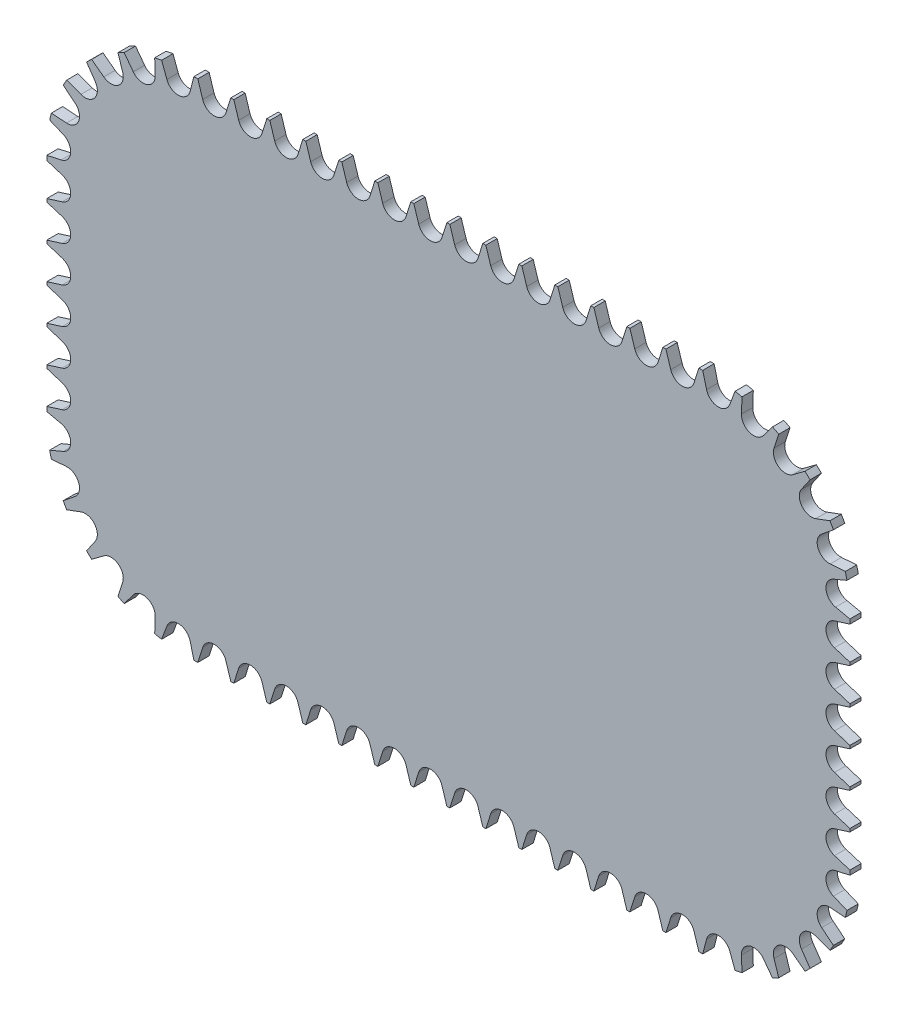
from build123d import *

# Parameters (mm, degrees)
AUFSATZ_LINEAR_AUSTRAGEN1_DEPTH = 4
SCHNITT_LINEAR_AUSTRAGEN1_DEPTH = 5
SPIEGELN2_COPY_1_DEPTH          = 5
SKIZZE4_OUTSIDE_W               = 354.422
SKIZZE4_OUTSIDE_H               = 249.422
SCHNITT_LINEAR_AUSTRAGEN2_DEPTH = 5


with BuildPart() as part:
    # Skizze1 → Aufsatz-Linear austragen1 (new body)
    with BuildSketch(Plane.XY):
        with BuildLine():
            Line((-92.5, -90), (92.5, -90))
            ThreePointArc((92.5, -90), (127.855339059, -75.355339059), (142.5, -40))
            Line((142.5, -40), (142.5, 40))
            ThreePointArc((142.5, 40), (127.855339059, 75.355339059), (92.5, 90))
            Line((92.5, 90), (-92.5, 90))
            ThreePointArc((-92.5, 90), (-127.855339059, 75.355339059), (-142.5, 40))
            Line((-142.5, 40), (-142.5, -40))
            ThreePointArc((-142.5, -40), (-127.855339059, -75.355339059), (-92.5, -90))
        make_face()
    extrude(amount=AUFSATZ_LINEAR_AUSTRAGEN1_DEPTH)

    # Skizze3 → Schnitt-Linear austragen1 (cut, through all)
    with BuildSketch(Plane.XY.offset(4)):
        with BuildLine():
            Line((-12.49822894, 90.2), (-10.450982888, 83.706965062))
            ThreePointArc((-10.450982888, 83.706965062), (-6.35, 80.7), (-2.249017112, 83.706965062))
            Line((-2.249017112, 83.706965062), (-0.20177106, 90.2))
            Line((-0.20177106, 90.2), (-12.49822894, 90.2))
        make_face()
        with BuildLine():
            Line((-115.221743509, 85.348794759), (-111.138194894, 79.901286172))
            ThreePointArc((-111.138194894, 79.901286172), (-106.27239465, 78.423487971), (-103.399819104, 82.619701654))
            Line((-103.399819104, 82.619701654), (-103.620303737, 89.424266712))
            Line((-103.620303737, 89.424266712), (-115.221743509, 85.348794759))
        make_face()
        with BuildLine():
            Line((-101.660918042, 89.872458206), (-99.2780093, 83.494961437))
            ThreePointArc((-99.2780093, 83.494961437), (-95.025864968, 80.705845428), (-91.087193292, 83.922484196))
            Line((-91.087193292, 83.922484196), (-89.381175989, 90.513404015))
            Line((-89.381175989, 90.513404015), (-101.660918042, 89.872458206))
        make_face()
        with BuildLine():
            Line((-126.985611723, 77.237422279), (-121.53161279, 73.162546239))
            ThreePointArc((-121.53161279, 73.162546239), (-116.446555008, 73.11686374), (-114.873880469, 77.95283255))
            Line((-114.873880469, 77.95283255), (-117.004281967, 84.419060861))
            Line((-117.004281967, 84.419060861), (-126.985611723, 77.237422279))
        make_face()
        with BuildLine():
            Line((-135.984667036, 66.137874436), (-129.602914915, 63.766385669))
            ThreePointArc((-129.602914915, 63.766385669), (-124.71135004, 65.156526888), (-124.566229357, 70.239718751))
            Line((-124.566229357, 70.239718751), (-128.433624578, 75.842751262))
            Line((-128.433624578, 75.842751262), (-135.984667036, 66.137874436))
        make_face()
        with BuildLine():
            Line((-141.488462669, 52.95109346), (-134.696959542, 52.475483988))
            ThreePointArc((-134.696959542, 52.475483988), (-130.395932339, 55.188612171), (-131.690144853, 60.106428099))
            Line((-131.690144853, 60.106428099), (-136.980620138, 64.391470732))
            Line((-136.980620138, 64.391470732), (-141.488462669, 52.95109346))
        make_face()
        with BuildLine():
            Line((-143.232042394, 38.794523972), (-136.581155829, 40.249318461))
            ThreePointArc((-136.581155829, 40.249318461), (-133.217437041, 44.063147961), (-135.843261134, 48.418024235))
            Line((-135.843261134, 48.418024235), (-142.125784298, 51.04111817))
            Line((-142.125784298, 51.04111817), (-143.232042394, 38.794523972))
        make_face()
        with BuildLine():
            Line((-142.7, 25.60177106), (-136.206965062, 27.649017112))
            ThreePointArc((-136.206965062, 27.649017112), (-133.2, 31.75), (-136.206965062, 35.850982888))
            Line((-136.206965062, 35.850982888), (-142.7, 37.89822894))
            Line((-142.7, 37.89822894), (-142.7, 25.60177106))
        make_face()
        with BuildLine():
            Line((-142.7, 12.90177106), (-136.206965062, 14.949017112))
            ThreePointArc((-136.206965062, 14.949017112), (-133.2, 19.05), (-136.206965062, 23.150982888))
            Line((-136.206965062, 23.150982888), (-142.7, 25.19822894))
            Line((-142.7, 25.19822894), (-142.7, 12.90177106))
        make_face()
        with BuildLine():
            Line((-142.7, 0.20177106), (-136.206965062, 2.249017112))
            ThreePointArc((-136.206965062, 2.249017112), (-133.2, 6.35), (-136.206965062, 10.450982888))
            Line((-136.206965062, 10.450982888), (-142.7, 12.49822894))
            Line((-142.7, 12.49822894), (-142.7, 0.20177106))
        make_face()
        with BuildLine():
            Line((-25.19822894, 90.2), (-23.150982888, 83.706965062))
            ThreePointArc((-23.150982888, 83.706965062), (-19.05, 80.7), (-14.949017112, 83.706965062))
            Line((-14.949017112, 83.706965062), (-12.90177106, 90.2))
            Line((-12.90177106, 90.2), (-25.19822894, 90.2))
        make_face()
        with BuildLine():
            Line((-37.89822894, 90.2), (-35.850982888, 83.706965062))
            ThreePointArc((-35.850982888, 83.706965062), (-31.75, 80.7), (-27.649017112, 83.706965062))
            Line((-27.649017112, 83.706965062), (-25.60177106, 90.2))
            Line((-25.60177106, 90.2), (-37.89822894, 90.2))
        make_face()
        with BuildLine():
            Line((-50.59822894, 90.2), (-48.550982888, 83.706965062))
            ThreePointArc((-48.550982888, 83.706965062), (-44.45, 80.7), (-40.349017112, 83.706965062))
            Line((-40.349017112, 83.706965062), (-38.30177106, 90.2))
            Line((-38.30177106, 90.2), (-50.59822894, 90.2))
        make_face()
        with BuildLine():
            Line((-63.29822894, 90.2), (-61.250982888, 83.706965062))
            ThreePointArc((-61.250982888, 83.706965062), (-57.15, 80.7), (-53.049017112, 83.706965062))
            Line((-53.049017112, 83.706965062), (-51.00177106, 90.2))
            Line((-51.00177106, 90.2), (-63.29822894, 90.2))
        make_face()
        with BuildLine():
            Line((-75.99822894, 90.2), (-73.950982888, 83.706965062))
            ThreePointArc((-73.950982888, 83.706965062), (-69.85, 80.7), (-65.749017112, 83.706965062))
            Line((-65.749017112, 83.706965062), (-63.70177106, 90.2))
            Line((-63.70177106, 90.2), (-75.99822894, 90.2))
        make_face()
        with BuildLine():
            Line((-88.69822894, 90.2), (-86.650982888, 83.706965062))
            ThreePointArc((-86.650982888, 83.706965062), (-82.55, 80.7), (-78.449017112, 83.706965062))
            Line((-78.449017112, 83.706965062), (-76.40177106, 90.2))
            Line((-76.40177106, 90.2), (-88.69822894, 90.2))
        make_face()
    schnitt_linear_austragen1 = extrude(amount=-SCHNITT_LINEAR_AUSTRAGEN1_DEPTH, mode=Mode.SUBTRACT)

    # Spiegeln1: Schnitt-Linear austragen1 across plane
    add(schnitt_linear_austragen1.mirror(Plane.ZX), mode=Mode.SUBTRACT)

    # Spiegeln2: Schnitt-Linear austragen1 across plane
    add(schnitt_linear_austragen1.mirror(Plane(origin=(0, 0, 0), x_dir=(0, 0, 1), z_dir=(1, 0, 0))), mode=Mode.SUBTRACT)

    # Spiegeln2 copy 1 sketch → Spiegeln2 copy 1 (cut, through all)
    with BuildSketch(Plane(origin=(0, 0, 4), x_dir=(-1, 0, 0), z_dir=(0, 0, 1))):
        with BuildLine():
            Line((-12.49822894, 90.2), (-10.450982888, 83.706965062))
            ThreePointArc((-10.450982888, 83.706965062), (-6.35, 80.7), (-2.249017112, 83.706965062))
            Line((-2.249017112, 83.706965062), (-0.20177106, 90.2))
            Line((-0.20177106, 90.2), (-12.49822894, 90.2))
        make_face()
        with BuildLine():
            Line((-115.221743509, 85.348794759), (-111.138194894, 79.901286172))
            ThreePointArc((-111.138194894, 79.901286172), (-106.27239465, 78.423487971), (-103.399819104, 82.619701654))
            Line((-103.399819104, 82.619701654), (-103.620303737, 89.424266712))
            Line((-103.620303737, 89.424266712), (-115.221743509, 85.348794759))
        make_face()
        with BuildLine():
            Line((-101.660918042, 89.872458206), (-99.2780093, 83.494961437))
            ThreePointArc((-99.2780093, 83.494961437), (-95.025864968, 80.705845428), (-91.087193292, 83.922484196))
            Line((-91.087193292, 83.922484196), (-89.381175989, 90.513404015))
            Line((-89.381175989, 90.513404015), (-101.660918042, 89.872458206))
        make_face()
        with BuildLine():
            Line((-126.985611723, 77.237422279), (-121.53161279, 73.162546239))
            ThreePointArc((-121.53161279, 73.162546239), (-116.446555008, 73.11686374), (-114.873880469, 77.95283255))
            Line((-114.873880469, 77.95283255), (-117.004281967, 84.419060861))
            Line((-117.004281967, 84.419060861), (-126.985611723, 77.237422279))
        make_face()
        with BuildLine():
            Line((-135.984667036, 66.137874436), (-129.602914915, 63.766385669))
            ThreePointArc((-129.602914915, 63.766385669), (-124.71135004, 65.156526888), (-124.566229357, 70.239718751))
            Line((-124.566229357, 70.239718751), (-128.433624578, 75.842751262))
            Line((-128.433624578, 75.842751262), (-135.984667036, 66.137874436))
        make_face()
        with BuildLine():
            Line((-141.488462669, 52.95109346), (-134.696959542, 52.475483988))
            ThreePointArc((-134.696959542, 52.475483988), (-130.395932339, 55.188612171), (-131.690144853, 60.106428099))
            Line((-131.690144853, 60.106428099), (-136.980620138, 64.391470732))
            Line((-136.980620138, 64.391470732), (-141.488462669, 52.95109346))
        make_face()
        with BuildLine():
            Line((-143.232042394, 38.794523972), (-136.581155829, 40.249318461))
            ThreePointArc((-136.581155829, 40.249318461), (-133.217437041, 44.063147961), (-135.843261134, 48.418024235))
            Line((-135.843261134, 48.418024235), (-142.125784298, 51.04111817))
            Line((-142.125784298, 51.04111817), (-143.232042394, 38.794523972))
        make_face()
        with BuildLine():
            Line((-142.7, 25.60177106), (-136.206965062, 27.649017112))
            ThreePointArc((-136.206965062, 27.649017112), (-133.2, 31.75), (-136.206965062, 35.850982888))
            Line((-136.206965062, 35.850982888), (-142.7, 37.89822894))
            Line((-142.7, 37.89822894), (-142.7, 25.60177106))
        make_face()
        with BuildLine():
            Line((-142.7, 12.90177106), (-136.206965062, 14.949017112))
            ThreePointArc((-136.206965062, 14.949017112), (-133.2, 19.05), (-136.206965062, 23.150982888))
            Line((-136.206965062, 23.150982888), (-142.7, 25.19822894))
            Line((-142.7, 25.19822894), (-142.7, 12.90177106))
        make_face()
        with BuildLine():
            Line((-142.7, 0.20177106), (-136.206965062, 2.249017112))
            ThreePointArc((-136.206965062, 2.249017112), (-133.2, 6.35), (-136.206965062, 10.450982888))
            Line((-136.206965062, 10.450982888), (-142.7, 12.49822894))
            Line((-142.7, 12.49822894), (-142.7, 0.20177106))
        make_face()
        with BuildLine():
            Line((-25.19822894, 90.2), (-23.150982888, 83.706965062))
            ThreePointArc((-23.150982888, 83.706965062), (-19.05, 80.7), (-14.949017112, 83.706965062))
            Line((-14.949017112, 83.706965062), (-12.90177106, 90.2))
            Line((-12.90177106, 90.2), (-25.19822894, 90.2))
        make_face()
        with BuildLine():
            Line((-37.89822894, 90.2), (-35.850982888, 83.706965062))
            ThreePointArc((-35.850982888, 83.706965062), (-31.75, 80.7), (-27.649017112, 83.706965062))
            Line((-27.649017112, 83.706965062), (-25.60177106, 90.2))
            Line((-25.60177106, 90.2), (-37.89822894, 90.2))
        make_face()
        with BuildLine():
            Line((-50.59822894, 90.2), (-48.550982888, 83.706965062))
            ThreePointArc((-48.550982888, 83.706965062), (-44.45, 80.7), (-40.349017112, 83.706965062))
            Line((-40.349017112, 83.706965062), (-38.30177106, 90.2))
            Line((-38.30177106, 90.2), (-50.59822894, 90.2))
        make_face()
        with BuildLine():
            Line((-63.29822894, 90.2), (-61.250982888, 83.706965062))
            ThreePointArc((-61.250982888, 83.706965062), (-57.15, 80.7), (-53.049017112, 83.706965062))
            Line((-53.049017112, 83.706965062), (-51.00177106, 90.2))
            Line((-51.00177106, 90.2), (-63.29822894, 90.2))
        make_face()
        with BuildLine():
            Line((-75.99822894, 90.2), (-73.950982888, 83.706965062))
            ThreePointArc((-73.950982888, 83.706965062), (-69.85, 80.7), (-65.749017112, 83.706965062))
            Line((-65.749017112, 83.706965062), (-63.70177106, 90.2))
            Line((-63.70177106, 90.2), (-75.99822894, 90.2))
        make_face()
        with BuildLine():
            Line((-88.69822894, 90.2), (-86.650982888, 83.706965062))
            ThreePointArc((-86.650982888, 83.706965062), (-82.55, 80.7), (-78.449017112, 83.706965062))
            Line((-78.449017112, 83.706965062), (-76.40177106, 90.2))
            Line((-76.40177106, 90.2), (-88.69822894, 90.2))
        make_face()
    extrude(amount=-SPIEGELN2_COPY_1_DEPTH, mode=Mode.SUBTRACT)

    # Skizze4 outside → Schnitt-Linear austragen2 (cut, through all)
    with BuildSketch(Plane.XY.offset(4)):
        Rectangle(SKIZZE4_OUTSIDE_W, SKIZZE4_OUTSIDE_H)
        with BuildLine():
            Line((92.92, -89.14), (-92.92, -89.14))
            ThreePointArc((-92.92, -89.14), (-127.370242379, -74.870242379), (-141.64, -40.42))
            Line((-141.64, -40.42), (-141.64, 40.42))
            ThreePointArc((-141.64, 40.42), (-127.370242379, 74.870242379), (-92.92, 89.14))
            Line((-92.92, 89.14), (92.92, 89.14))
            ThreePointArc((92.92, 89.14), (127.370242379, 74.870242379), (141.64, 40.42))
            Line((141.64, 40.42), (141.64, -40.42))
            ThreePointArc((141.64, -40.42), (127.370242379, -74.870242379), (92.92, -89.14))
        make_face(mode=Mode.SUBTRACT)
    extrude(amount=-SCHNITT_LINEAR_AUSTRAGEN2_DEPTH, mode=Mode.SUBTRACT)


solid = part.part
